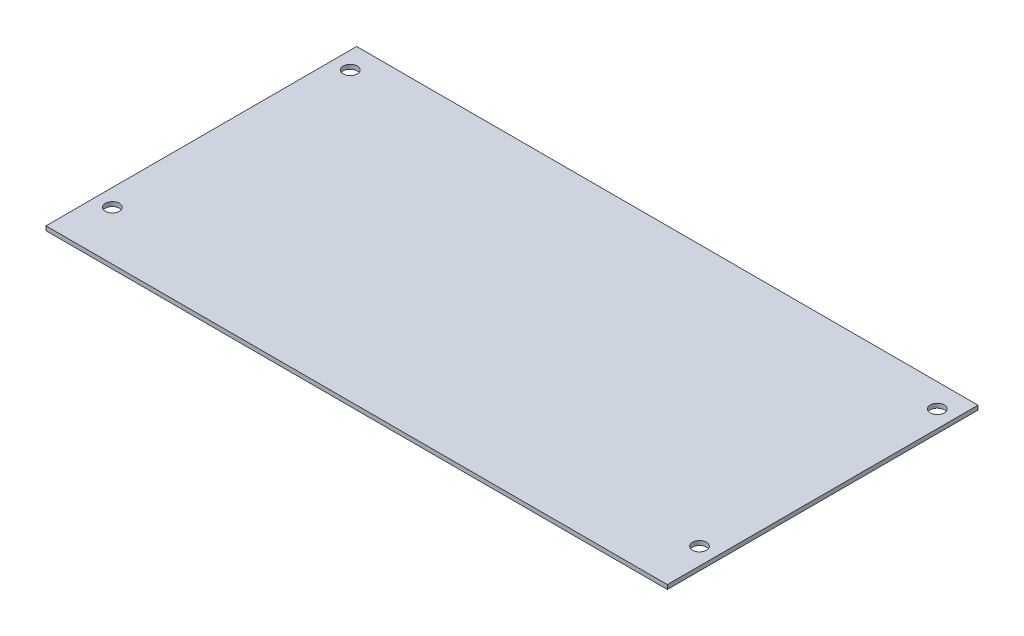
from build123d import *

# Parameters (mm, degrees)
SKETCH2_W           = 290
SKETCH2_H           = 145
SKETCH2_R           = 3.25
BOSS_EXTRUDE1_DEPTH = 2


with BuildPart() as part:
    # Sketch2 → Boss-Extrude1 (new body)
    with BuildSketch(Plane(origin=(0, 0, 0), x_dir=(1, 0, 0), z_dir=(0, 1, 0))):
        with Locations((-145, 72.5)):
            Rectangle(SKETCH2_W, SKETCH2_H)
        with Locations((-282, 134)):
            Circle(SKETCH2_R, mode=Mode.SUBTRACT)
        with Locations((-282, 23)):
            Circle(SKETCH2_R, mode=Mode.SUBTRACT)
        with Locations((-8, 23)):
            Circle(SKETCH2_R, mode=Mode.SUBTRACT)
        with Locations((-8, 134)):
            Circle(SKETCH2_R, mode=Mode.SUBTRACT)
    extrude(amount=BOSS_EXTRUDE1_DEPTH)


solid = part.part
